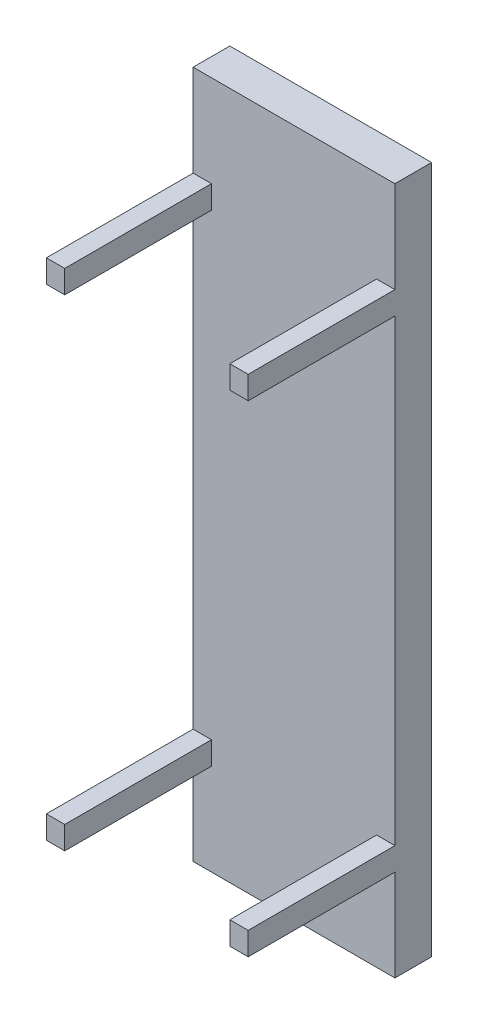
from build123d import *

# Parameters (mm, degrees)
SKETCH1_W           = 440
SKETCH1_H           = 1500
BOSS_EXTRUDE1_DEPTH = 80
SKETCH4_W           = 40
SKETCH4_H           = 50
BOSS_EXTRUDE4_DEPTH = 320


with BuildPart() as part:
    # Sketch1 → Boss-Extrude1 (new body)
    with BuildSketch(Plane.XY):
        Rectangle(SKETCH1_W, SKETCH1_H)
    extrude(amount=BOSS_EXTRUDE1_DEPTH)

    # Sketch4 → Boss-Extrude4 (add)
    with BuildSketch(Plane.XY.offset(80)):
        with Locations((-200, 525)):
            Rectangle(SKETCH4_W, SKETCH4_H)
        with Locations((-200, -525)):
            Rectangle(SKETCH4_W, SKETCH4_H)
        with Locations((200, -525)):
            Rectangle(SKETCH4_W, SKETCH4_H)
        with Locations((200, 525)):
            Rectangle(SKETCH4_W, SKETCH4_H)
    extrude(amount=BOSS_EXTRUDE4_DEPTH)


solid = part.part
